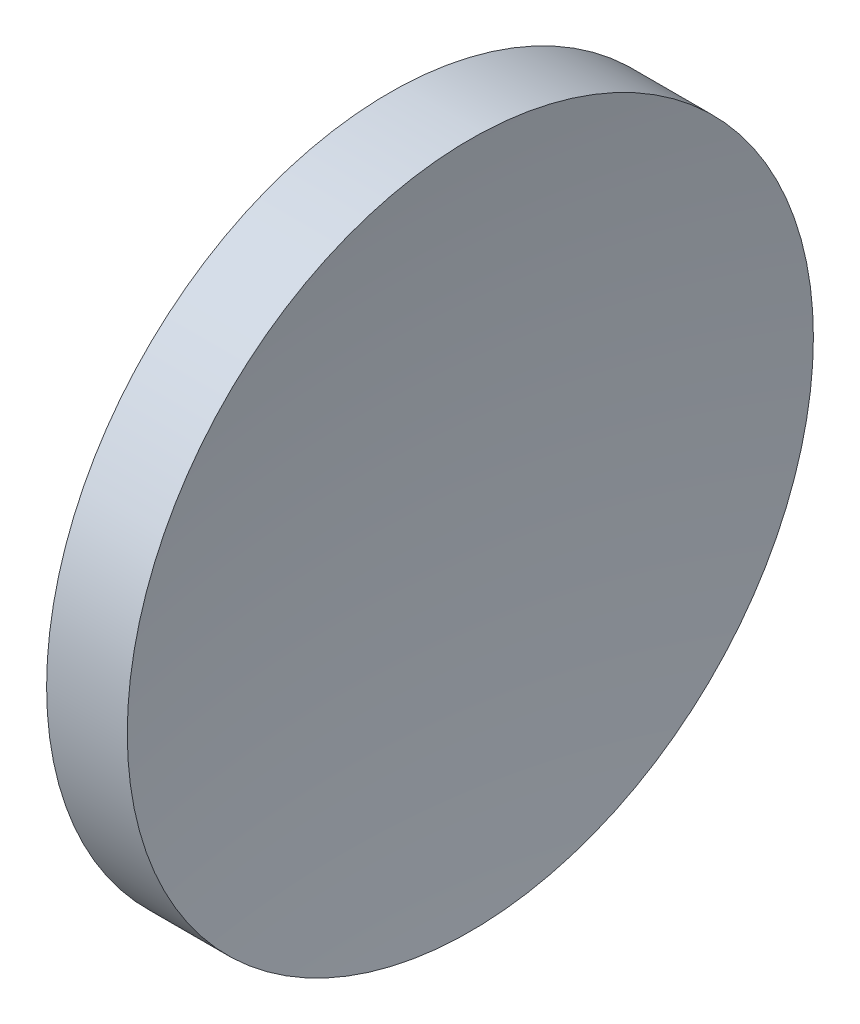
from build123d import *


with BuildPart() as part:
    # 草图1 → 旋转1 (revolve)
    with BuildSketch(Plane.XY, mode=Mode.PRIVATE) as revolve_1_sk:
        with BuildLine():
            Line((57.532337053, 32.610768129), (57.532337053, 45.110768129))
            Line((57.532337053, 45.110768129), (60.471373375, 45.110768129))
            ThreePointArc((60.471373375, 45.110768129), (59.764448476, 38.878602813), (59.532337053, 32.610768129))
            Line((59.532337053, 32.610768129), (57.532337053, 32.610768129))
        make_face()
    revolve(revolve_1_sk.sketch.rotate(Axis((56.10091508, 32.610768129, 0), (1, 0, 0)), 90), axis=Axis((56.10091508, 32.610768129, 0), (1, 0, 0)))  # turned: the seam where the file's is


solid = part.part
